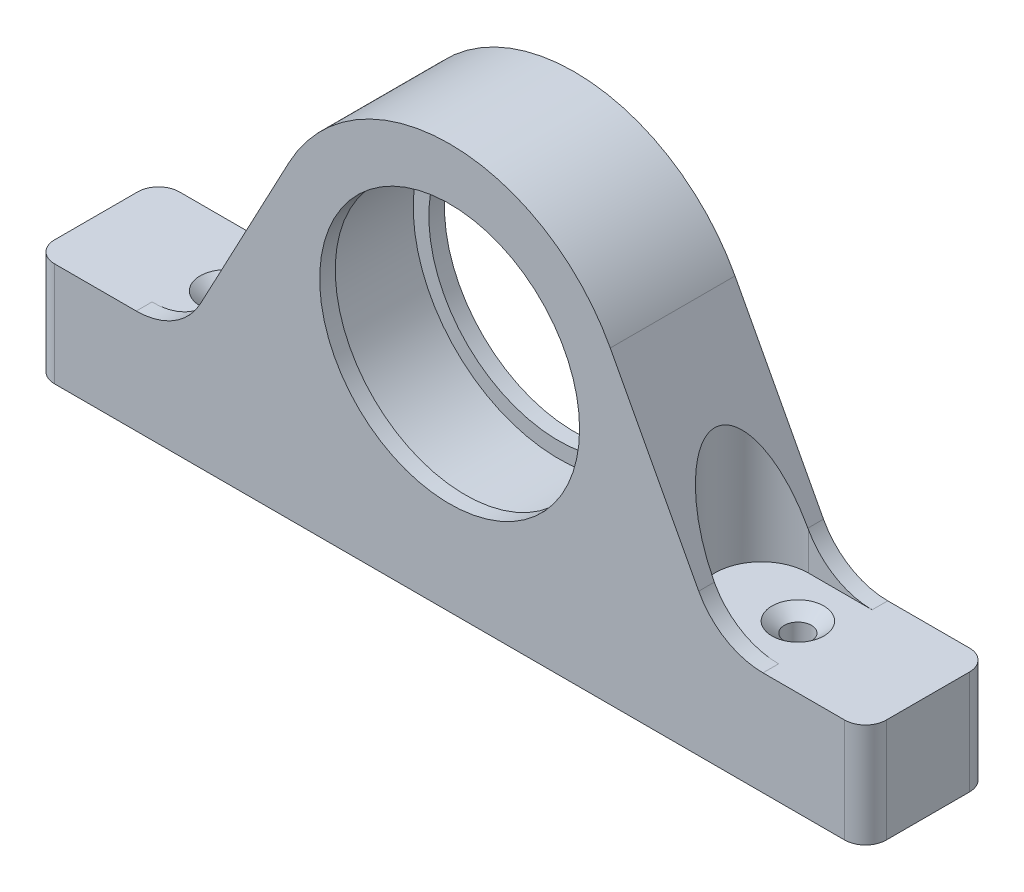
from build123d import *

# Parameters (mm, degrees)
SKETCH1_R                             = 31.75
BOSS_EXTRUDE1_DEPTH                   = 15.24
FILLET1_R                             = 5.08
CUT_EXTRUDE2_DEPTH                    = 74.66
F_1_4_0_26_DIAMETER_HOLE1_D           = 6.604
F_1_4_0_26_DIAMETER_HOLE1_DEPTH       = 25.4
F_1_4_0_26_DIAMETER_HOLE1_CSINK_D     = 12.7
F_1_4_0_26_DIAMETER_HOLE1_CSINK_ANGLE = 100
SKETCH5_R                             = 35.56
CUT_EXTRUDE3_DEPTH                    = 11.43


with BuildPart() as part:
    # Sketch1 → Boss-Extrude1 (new body, symmetric)
    with BuildSketch(Plane.XY):
        with BuildLine():
            Line((-101.6, -54.61), (101.6, -54.61))
            Line((101.6, -54.61), (101.6, -29.21))
            Line((101.6, -29.21), (76.557273058, -29.21))
            ThreePointArc((76.557273058, -29.21), (67.399896086, -26.670434606), (60.858464857, -19.777204386))
            Line((60.858464857, -19.777204386), (39.247020503, 20.868010966))
            ThreePointArc((39.247020503, 20.868010966), (0, 44.45), (-39.247020503, 20.868010966))
            Line((-39.247020503, 20.868010966), (-60.858464857, -19.777204386))
            ThreePointArc((-60.858464857, -19.777204386), (-67.399896086, -26.670434606), (-76.557273058, -29.21))
            Line((-76.557273058, -29.21), (-101.6, -29.21))
            Line((-101.6, -29.21), (-101.6, -54.61))
        make_face()
        Circle(SKETCH1_R, mode=Mode.SUBTRACT)
    extrude(amount=BOSS_EXTRUDE1_DEPTH, both=True)

    # Fillet1
    fillet1_edges = [part.edges().sort_by_distance(p)[0] for p in [
        (101.6, -41.91, 15.24),
        (101.6, -41.91, -15.24),
        (-101.6, -41.91, -15.24),
        (-101.6, -41.91, 15.24),
    ]]
    fillet(fillet1_edges, radius=FILLET1_R)

    # Sketch2 → Cut-Extrude2 (cut, through all)
    with BuildSketch(Plane(origin=(0, -29.21, 0), x_dir=(1, 0, 0), z_dir=(0, 1, 0))):
        with BuildLine():
            Line((-93.98, 11.43), (-60.96, 11.43))
            ThreePointArc((-60.96, 11.43), (-49.53, 0), (-60.96, -11.43))
            Line((-60.96, -11.43), (-93.98, -11.43))
            Line((-93.98, -11.43), (-93.98, 11.43))
        make_face()
        with BuildLine():
            Line((93.98, 11.43), (93.98, -11.43))
            Line((93.98, -11.43), (60.96, -11.43))
            ThreePointArc((60.96, -11.43), (49.53, 0), (60.96, 11.43))
            Line((60.96, 11.43), (93.98, 11.43))
        make_face()
    extrude(amount=CUT_EXTRUDE2_DEPTH, mode=Mode.SUBTRACT)

    # 1/4 (0.26) Diameter Hole1
    with Locations(Plane(origin=(0, -29.21, 0), x_dir=(1, 0, 0), z_dir=(0, 1, 0))):
        with Locations((-69.85, 0), (69.85, 0)):
            CounterSinkHole(F_1_4_0_26_DIAMETER_HOLE1_D / 2, F_1_4_0_26_DIAMETER_HOLE1_CSINK_D / 2, depth=F_1_4_0_26_DIAMETER_HOLE1_DEPTH, counter_sink_angle=F_1_4_0_26_DIAMETER_HOLE1_CSINK_ANGLE)

    # Sketch5 → Cut-Extrude3 (cut, symmetric)
    with BuildSketch(Plane.XY):
        Circle(SKETCH5_R)
    extrude(amount=CUT_EXTRUDE3_DEPTH, both=True, mode=Mode.SUBTRACT)


solid = part.part
